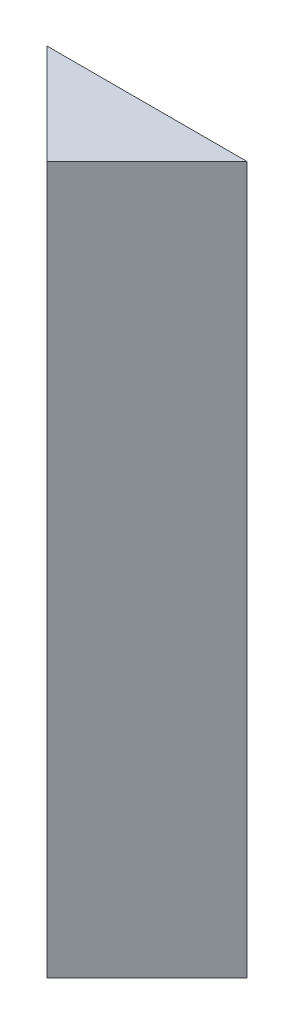
from build123d import *

# Parameters (mm, degrees)
EXTRUDE_1_DEPTH = 15


with BuildPart() as part:
    # 草图1 → 凸台-拉伸1 (new body)
    with BuildSketch(Plane(origin=(0, 0, 0), x_dir=(1, 0, 0), z_dir=(0, 1, 0))):
        Polygon((0, 0), (2.121320344, -2.121320344), (4.242640687, 0), align=None)
    extrude(amount=EXTRUDE_1_DEPTH)


solid = part.part
